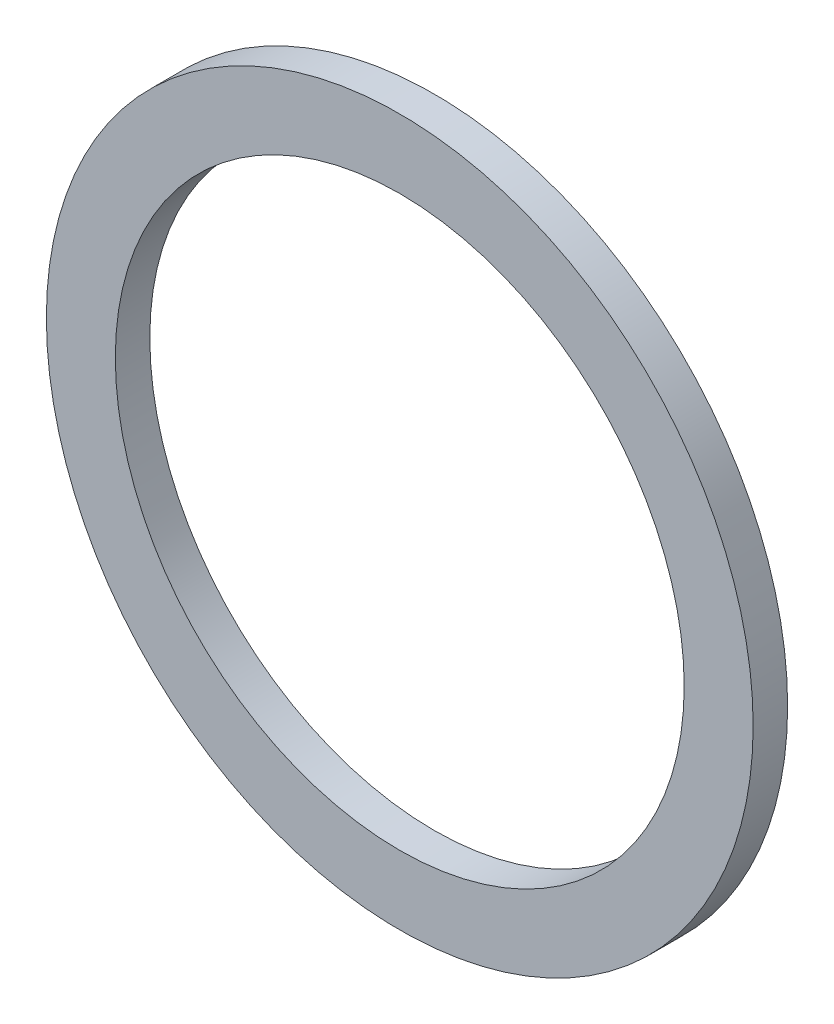
from build123d import *

# Parameters (mm, degrees)
ESQUISSE1_R      = 10.25
ESQUISSE1_R_2    = 8.25
EXTRUSION1_DEPTH = 0.5


with BuildPart() as part:
    # Esquisse1 → Extrusion1 (new body, symmetric)
    with BuildSketch(Plane.XY):
        Circle(ESQUISSE1_R)
        Circle(ESQUISSE1_R_2, mode=Mode.SUBTRACT)
    extrude(amount=EXTRUSION1_DEPTH, both=True)


solid = part.part
